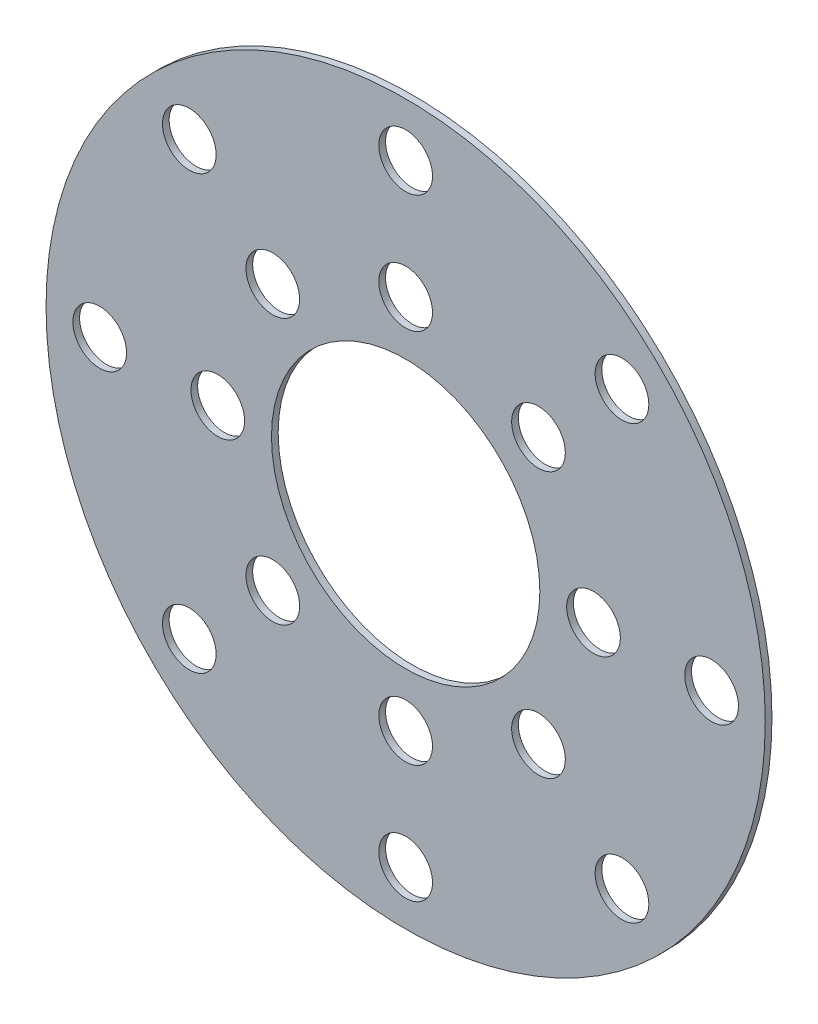
from build123d import *

# Parameters (mm, degrees)
SKETCH4_R           = 42.545
BOSS_EXTRUDE2_DEPTH = 0.79375
SKETCH5_R           = 15.875
CUT_EXTRUDE5_DEPTH  = 1.79375
SKETCH9_R           = 3.175
CUT_EXTRUDE12_DEPTH = 1.79375


with BuildPart() as part:
    # Sketch4 → Boss-Extrude2 (new body)
    with BuildSketch(Plane.XY):
        Circle(SKETCH4_R)
    extrude(amount=BOSS_EXTRUDE2_DEPTH)

    # Sketch5 → Cut-Extrude5 (cut, through all)
    with BuildSketch(Plane.XY.offset(0.79375)):
        Circle(SKETCH5_R)
    extrude(amount=-CUT_EXTRUDE5_DEPTH, mode=Mode.SUBTRACT)

    # Sketch9 → Cut-Extrude12 (cut, through all)
    with BuildSketch(Plane.XY.offset(0.79375)):
        with Locations((22.225, 0)):
            Circle(SKETCH9_R)
        with Locations((36.195, 0)):
            Circle(SKETCH9_R)
        with Locations((15.715448212, -15.715448212)):
            Circle(SKETCH9_R)
        with Locations((25.593729945, -25.593729945)):
            Circle(SKETCH9_R)
        with Locations((0, -22.225)):
            Circle(SKETCH9_R)
        with Locations((0, -36.195)):
            Circle(SKETCH9_R)
        with Locations((-15.715448212, -15.715448212)):
            Circle(SKETCH9_R)
        with Locations((-25.593729945, -25.593729945)):
            Circle(SKETCH9_R)
        with Locations((-22.225, 0)):
            Circle(SKETCH9_R)
        with Locations((-36.195, 0)):
            Circle(SKETCH9_R)
        with Locations((-15.715448212, 15.715448212)):
            Circle(SKETCH9_R)
        with Locations((-25.593729945, 25.593729945)):
            Circle(SKETCH9_R)
        with Locations((0, 22.225)):
            Circle(SKETCH9_R)
        with Locations((0, 36.195)):
            Circle(SKETCH9_R)
        with Locations((15.715448212, 15.715448212)):
            Circle(SKETCH9_R)
        with Locations((25.593729945, 25.593729945)):
            Circle(SKETCH9_R)
    extrude(amount=-CUT_EXTRUDE12_DEPTH, mode=Mode.SUBTRACT)


solid = part.part
